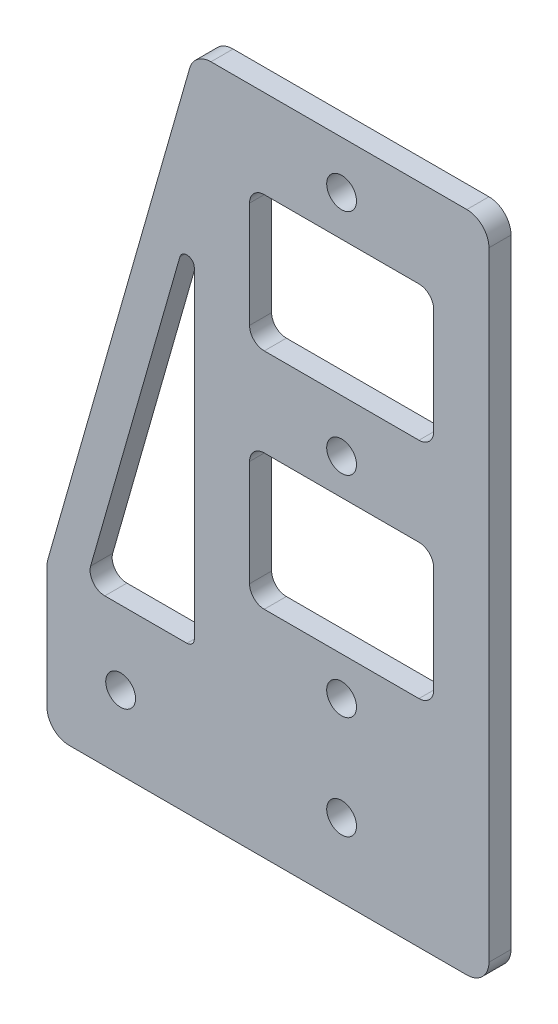
from build123d import *

# Parameters (mm, degrees)
EXTRUDE_1_DEPTH     = 1.5
CUT_EXTRUDE_1_DEPTH = 4
FILLET_1_R          = 1
SKETCH_3_W          = 25
SKETCH_3_H          = 18.375
CUT_EXTRUDE_2_DEPTH = 4
FILLET_2_R          = 2
SKETCH_4_R          = 2.025
CUT_EXTRUDE_3_DEPTH = 10
FILLET_3_R          = 3
FILLET_4_R          = 2


with BuildPart() as part:
    # 草图1 → 凸台-拉伸1 (new body, symmetric)
    with BuildSketch(Plane.XY):
        Polygon((0, 0), (-60, 0), (-60, 20), (-40, 90), (0, 90), align=None)
    extrude(amount=EXTRUDE_1_DEPTH, both=True)

    # 草图2 → 切除-拉伸1 (cut, through all)
    with BuildSketch(Plane.XY.offset(1.5)):
        Polygon((-40, 71.799725277), (-54.799921508, 20), (-40, 20), align=None)
    extrude(amount=-CUT_EXTRUDE_1_DEPTH, mode=Mode.SUBTRACT)

    # 圆角1
    fillet_1_edges = [part.edges().sort_by_distance(p)[0] for p in [
        (-40, 71.799725277, 0),
        (-40, 20, 0),
    ]]
    fillet(fillet_1_edges, radius=FILLET_1_R)

    # 草图3 → 切除-拉伸2 (cut, through all)
    with BuildSketch(Plane.XY.offset(1.5)):
        with Locations((-20, 68.8125)):
            Rectangle(SKETCH_3_W, SKETCH_3_H)
        with Locations((-20, 38.4375)):
            Rectangle(SKETCH_3_W, SKETCH_3_H)
    extrude(amount=-CUT_EXTRUDE_2_DEPTH, mode=Mode.SUBTRACT)

    # 圆角2
    fillet_2_edges = [part.edges().sort_by_distance(p)[0] for p in [
        (-7.5, 78, 0),
        (-7.5, 59.625, 0),
        (-32.5, 59.625, 0),
        (-32.5, 78, 0),
        (-7.5, 47.625, 0),
        (-7.5, 29.25, 0),
        (-32.5, 29.25, 0),
        (-32.5, 47.625, 0),
    ]]
    fillet(fillet_2_edges, radius=FILLET_2_R)

    # 草图4 → 切除-拉伸3 (cut)
    with BuildSketch(Plane.XY.offset(1.5)):
        with Locations((-50, 10)):
            Circle(SKETCH_4_R)
        with Locations((-20, 10)):
            Circle(SKETCH_4_R)
        with Locations((-20, 24)):
            Circle(SKETCH_4_R)
        with Locations((-20, 52.5)):
            Circle(SKETCH_4_R)
        with Locations((-20, 83.5)):
            Circle(SKETCH_4_R)
    extrude(amount=-CUT_EXTRUDE_3_DEPTH, mode=Mode.SUBTRACT)

    # 圆角3
    fillet_3_edges = [part.edges().sort_by_distance(p)[0] for p in [
        (0, 0, 0),
        (-60, 0, 0),
        (-60, 20, 0),
        (-40, 90, 0),
        (0, 90, 0),
    ]]
    fillet(fillet_3_edges, radius=FILLET_3_R)

    # 圆角4
    fillet_4_edges = [part.edges().sort_by_distance(p)[0] for p in [
        (-54.799921508, 20, 0),
    ]]
    fillet(fillet_4_edges, radius=FILLET_4_R)


solid = part.part
